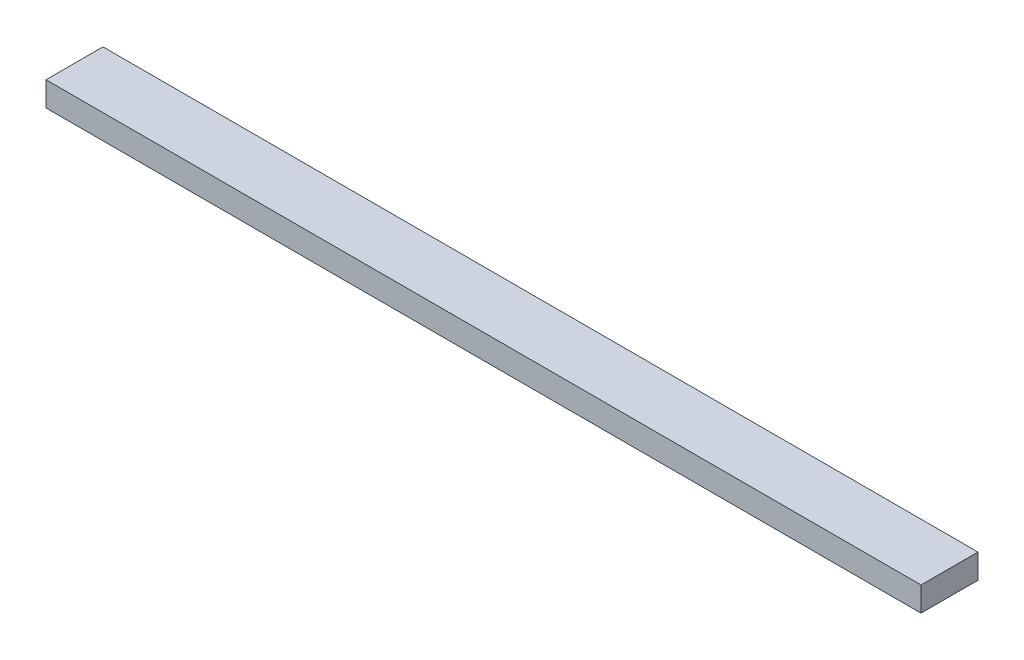
from build123d import *

# Parameters (mm, degrees)
SKETCH1_W           = 1365.2754
SKETCH1_H           = 88.9
BOSS_EXTRUDE1_DEPTH = 38.1


with BuildPart() as part:
    # Sketch1 → Boss-Extrude1 (new body)
    with BuildSketch(Plane(origin=(0, 0, 0), x_dir=(1, 0, 0), z_dir=(0, 1, 0))):
        with Locations((682.6377, 44.45)):
            Rectangle(SKETCH1_W, SKETCH1_H)
    extrude(amount=BOSS_EXTRUDE1_DEPTH)


solid = part.part
